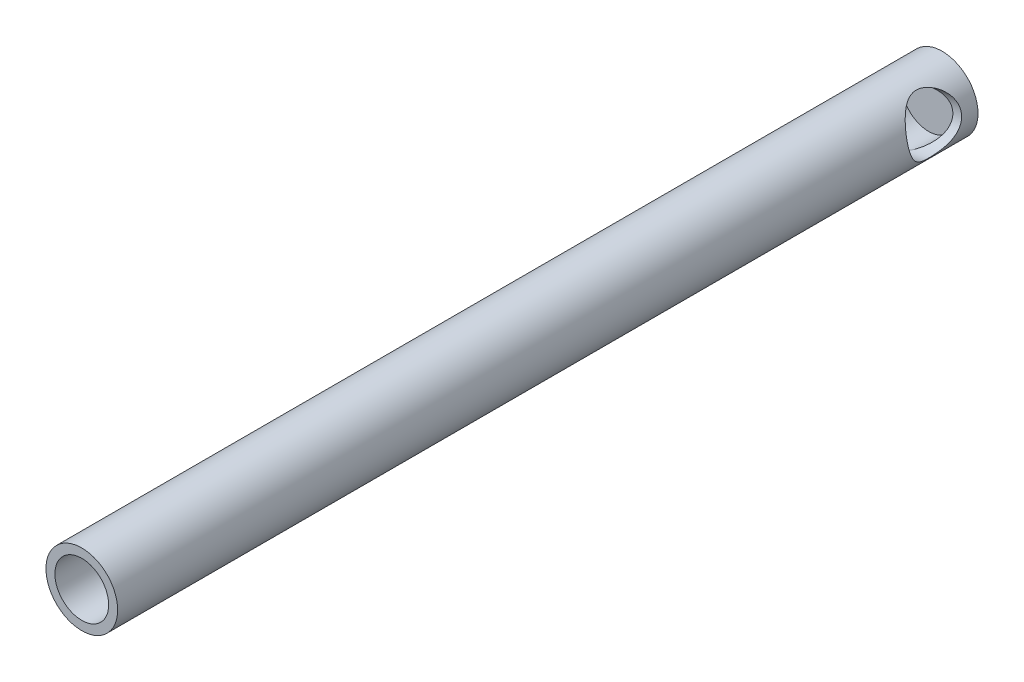
from build123d import *

# Parameters (mm, degrees)
SKETCH1_R                           = 3.175
BOSS_EXTRUDE1_DEPTH                 = 76.2
SKETCH5_R                           = 2.38125
CUT_EXTRUDE3_DEPTH                  = 75
F_3_16_0_1875_DIAMETER_HOLE2_REACH  = 74.798
F_3_16_0_1875_DIAMETER_HOLE2_BORE_R = 2.38125


with BuildPart() as part:
    # Sketch1 → Boss-Extrude1 (new body)
    with BuildSketch(Plane.XY):
        with Locations(Location((0, 0, 0), (0, 0, 180))):
            Circle(SKETCH1_R)
    extrude(amount=BOSS_EXTRUDE1_DEPTH)

    # Sketch5 → Cut-Extrude3 (cut)
    with BuildSketch(Plane.XY.offset(76.2)):
        Circle(SKETCH5_R)
    extrude(amount=-CUT_EXTRUDE3_DEPTH, mode=Mode.SUBTRACT)

    # 3/16 (0.1875) Diameter Hole2 bore (on position points) → 3/16 (0.1875) Diameter Hole2 (cut, up to next)
    with BuildSketch(Plane(origin=(3.083465245, 0.756879835, 3.778656036), x_dir=(-0.238387349479, 0.971170155847, 0), z_dir=(0.971170155847, 0.238387349479, 0)), mode=Mode.PRIVATE) as f_3_16_0_1875_diameter_hole2_sk1:
        Circle(F_3_16_0_1875_DIAMETER_HOLE2_BORE_R)
    f_3_16_0_1875_diameter_hole2_tool1 = extrude(f_3_16_0_1875_diameter_hole2_sk1.sketch, amount=-F_3_16_0_1875_DIAMETER_HOLE2_REACH, mode=Mode.PRIVATE) & part.part
    add(f_3_16_0_1875_diameter_hole2_tool1.solids().sort_by_distance((3.083465, 0.75688, 3.778656))[0], mode=Mode.SUBTRACT)


solid = part.part
